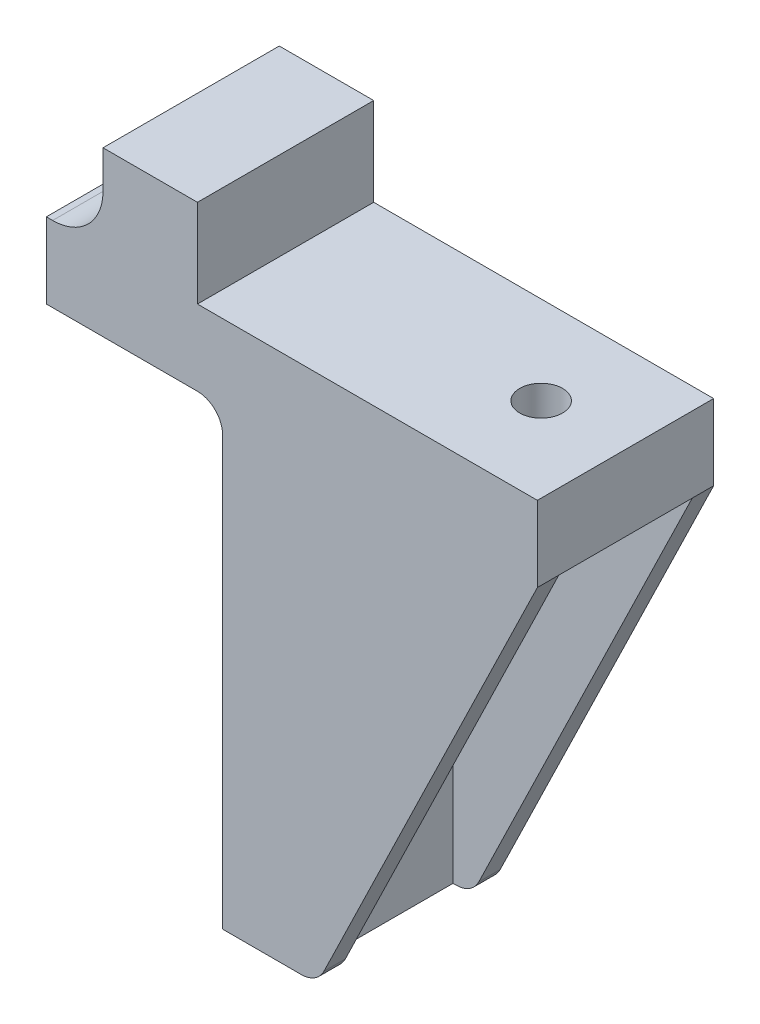
from build123d import *

# Parameters (mm, degrees)
BOSS_EXTRUDE1_DEPTH = 14
SKETCH2_R           = 1.7
CUT_EXTRUDE1_DEPTH  = 10
SKETCH3_R           = 1.7
CUT_EXTRUDE2_DEPTH  = 10
SKETCH14_W          = 14
SKETCH14_H          = 6
BOSS_EXTRUDE3_DEPTH = 14
FILLET8_R           = 2
SKETCH17_W          = 1.5
SKETCH17_H          = 1.7
SKETCH18_W          = 19
SKETCH18_H          = 1.7
SKETCH20_W          = 19
SKETCH20_H          = 1.7
SKETCH19_W          = 1.5
SKETCH19_H          = 1.7
FILLET9_R           = 8
SKETCH21_W          = 7.5
SKETCH21_H          = 7
BOSS_EXTRUDE4_DEPTH = 14
FILLET10_R          = 4
FILLET11_R          = 2
FILLET12_R          = 2


with BuildPart() as part:
    # Sketch1 → Boss-Extrude1 (new body)
    with BuildSketch(Plane.XY):
        Polygon((0, 0), (25, 0), (25, -6), (6, -6), (6, -42), (0, -42), (0, -5.547169811), align=None)
    extrude(amount=BOSS_EXTRUDE1_DEPTH)

    # Sketch2 → Cut-Extrude1 (cut)
    with BuildSketch(Plane(origin=(6, 0, 0), x_dir=(0, 0, -1), z_dir=(1, 0, 0))):
        with Locations((-7, -17.78)):
            Circle(SKETCH2_R)
        with Locations((-7, -34.058)):
            Circle(SKETCH2_R)
    extrude(amount=-CUT_EXTRUDE1_DEPTH, mode=Mode.SUBTRACT)

    # Sketch3 → Cut-Extrude2 (cut)
    with BuildSketch(Plane.XZ.offset(6)):
        with Locations((18.3, 7)):
            Circle(SKETCH3_R)
    extrude(amount=-CUT_EXTRUDE2_DEPTH, mode=Mode.SUBTRACT)

    # Sketch14 → Boss-Extrude3 (add)
    with BuildSketch(Plane(origin=(0, 0, 0), x_dir=(-1, 0, 0), z_dir=(0, 0, -1))):
        with Locations((7, -3)):
            Rectangle(SKETCH14_W, SKETCH14_H)
    extrude(amount=-BOSS_EXTRUDE3_DEPTH)

    # Fillet8
    fillet8_edges = [part.edges().sort_by_distance(p)[0] for p in [
        (0, -6, 7),
    ]]
    fillet(fillet8_edges, radius=FILLET8_R)

    # Sketch17 → Loft2 section 0
    with BuildSketch(Plane.XZ.offset(42)):
        with Locations((6.75, 13.15)):
            Rectangle(SKETCH17_W, SKETCH17_H)
    # Sketch18 → Loft2 section 1
    with BuildSketch(Plane.XZ.offset(6)):
        with Locations((15.5, 13.15)):
            Rectangle(SKETCH18_W, SKETCH18_H)
    loft()

    # Sketch20 → Loft3 section 0
    with BuildSketch(Plane.XZ.offset(6)):
        with Locations((15.5, 0.85)):
            Rectangle(SKETCH20_W, SKETCH20_H)
    # Sketch19 → Loft3 section 1
    with BuildSketch(Plane.XZ.offset(42)):
        with Locations((6.75, 0.85)):
            Rectangle(SKETCH19_W, SKETCH19_H)
    loft()

    # Fillet9
    fillet9_edges = [part.edges().sort_by_distance(p)[0] for p in [
        (6, -6, 7),
    ]]
    fillet(fillet9_edges, radius=FILLET9_R)

    # Sketch21 → Boss-Extrude4 (add)
    with BuildSketch(Plane(origin=(0, 0, 0), x_dir=(-1, 0, 0), z_dir=(0, 0, -1))):
        with Locations((5.75, 3.5)):
            Rectangle(SKETCH21_W, SKETCH21_H)
    extrude(amount=-BOSS_EXTRUDE4_DEPTH)

    # Fillet10
    fillet10_edges = [part.edges().sort_by_distance(p)[0] for p in [
        (-9.5, 0, 7),
    ]]
    fillet(fillet10_edges, radius=FILLET10_R)

    # Fillet11
    fillet11_edges = [part.edges().sort_by_distance(p)[0] for p in [
        (7.5, -42, 0.85),
    ]]
    fillet(fillet11_edges, radius=FILLET11_R)

    # Fillet12
    fillet12_edges = [part.edges().sort_by_distance(p)[0] for p in [
        (7.5, -42, 13.15),
    ]]
    fillet(fillet12_edges, radius=FILLET12_R)


solid = part.part
